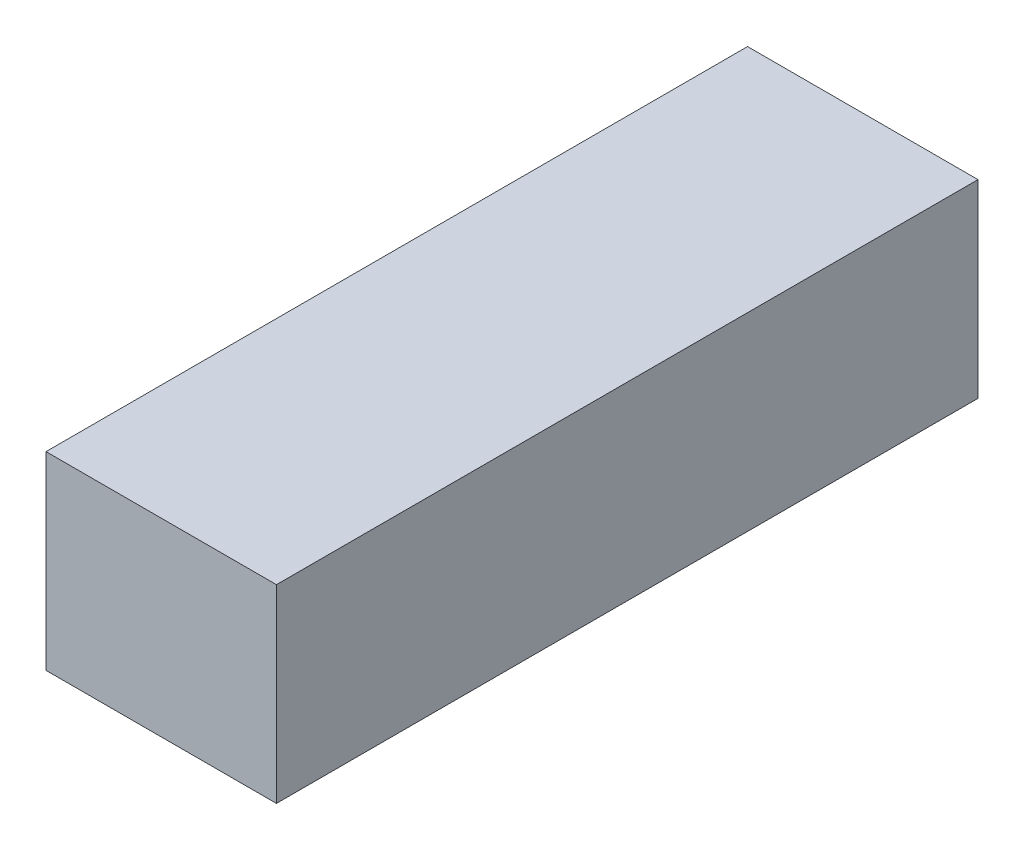
from build123d import *

# Parameters (mm, degrees)
SKETCH1_W           = 45
SKETCH1_H           = 37
BOSS_EXTRUDE1_DEPTH = 137


with BuildPart() as part:
    # Sketch1 → Boss-Extrude1 (new body)
    with BuildSketch(Plane.XY):
        Rectangle(SKETCH1_W, SKETCH1_H)
    extrude(amount=BOSS_EXTRUDE1_DEPTH)


solid = part.part
